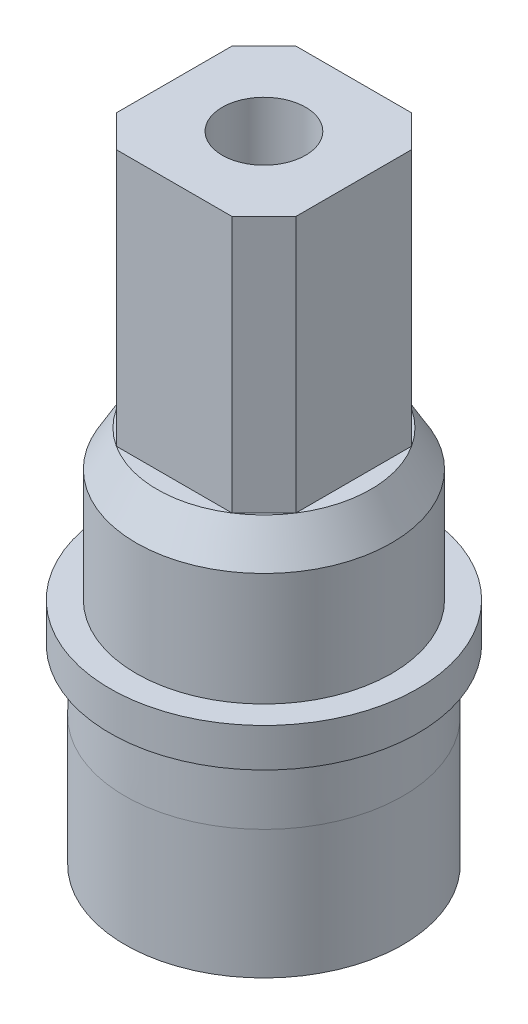
from build123d import *
from build123d.topology import SkipClean

# Parameters (mm, degrees)
SKETCH2_R                = 1.295
BOSS_EXTRUDE1_DEPTH      = 7.7
SKETCH3_R                = 2.7
BOSS_EXTRUDE4_DEPTH      = 6
SKETCH5_R                = 4.484484463
CUT_EXTRUDE1_DEPTH       = 1
SKETCH8_R                = 4.315
BOSS_EXTRUDE8_DEPTH      = 8
CUT_EXTRUDE4_DEPTH       = 10.2
SKETCH14_W               = 2.622578867
SKETCH14_H               = 4.71707074
CUT_EXTRUDE11_DEPTH      = 19.337852928
CUT_EXTRUDE11_DEPTH_BACK = 19.337852928
SKETCH16_R               = 1.295
BOSS_EXTRUDE9_DEPTH      = 5
CUT_EXTRUDE12_DEPTH      = 14
SKETCH22_R               = 4.315
CUT_EXTRUDE14_DEPTH      = 4


with BuildPart() as part:
    # Sketch1 → Revolve1 (revolve)
    with BuildSketch(Plane.XY, mode=Mode.PRIVATE) as revolve1_sk:
        Polygon((-2.7, 0), (-2.7, 5.54), (-1.295, 5.54), (-1.295, 8.3), (-3.32, 8.3), (-3.97, 7.184383121), (-3.97, 3.67), (-4.785, 3.67), (-4.785, 2.47), (-4.28, 2.47), (-4.325, 0), align=None)
    revolve(revolve1_sk.sketch.rotate(Axis((0, 0, 0), (0, 1, 0)), 270), axis=Axis((0, 0, 0), (0, 1, 0)))

    # Sketch2 → Boss-Extrude1 (add)
    with BuildSketch(Plane(origin=(0, 8.3, 0), x_dir=(1, 0, 0), z_dir=(0, 1, 0))):
        Polygon((1.799527716, 2.79), (-1.799527716, 2.79), (-2.79, 1.799527716), (-2.79, -1.799527716), (-1.799527716, -2.79), (1.799527716, -2.79), (2.79, -1.799527716), (2.79, 1.799527716), align=None)
        with Locations(Location((0, 0, 0), (0, 0, 90))):
            Circle(SKETCH2_R, mode=Mode.SUBTRACT)
    extrude(amount=BOSS_EXTRUDE1_DEPTH)

    # Sketch3 → Boss-Extrude4 (add)
    with BuildSketch(Plane.XZ.offset(-5.54)):
        with Locations(Location((0, 0, 0), (0, 0, 270))):
            Circle(SKETCH3_R)
    extrude(amount=BOSS_EXTRUDE4_DEPTH)

    # Sketch5 → Cut-Extrude1 (cut)
    with BuildSketch(Plane.XZ.offset(0.46)):
        Circle(SKETCH5_R)
    extrude(amount=-CUT_EXTRUDE1_DEPTH, mode=Mode.SUBTRACT)


with BuildPart() as body_2:
    # Sketch8 → Boss-Extrude8 (new body)
    with BuildSketch(Plane.XZ.offset(-0.54)):
        with Locations(Location((0, 0, 0), (0, 0, 270))):
            Circle(SKETCH8_R)
    extrude(amount=BOSS_EXTRUDE8_DEPTH)


with BuildPart() as cut_extrude4_tool:
    # Sketch13 → Cut-Extrude4 (new body)
    with BuildSketch(Plane.XZ.offset(7.46)):
        with BuildLine():
            ThreePointArc((1.6, 0), (-0.71250829, 1.432596222), (-0.96541492, -1.275920857))
            Line((-0.96541492, -1.275920857), (1.145236615, -1.117333029))
            ThreePointArc((1.145236615, -1.117333029), (1.481954551, -0.603167231), (1.6, 0))
        make_face()
    extrude(amount=-CUT_EXTRUDE4_DEPTH)


with BuildPart() as part_1:
    add(part.part)

    # Cut-Extrude4: cut by cut_extrude4_tool
    add(cut_extrude4_tool.part, mode=Mode.SUBTRACT)

    # Sketch14 → Cut-Extrude11 (cut, two sides)
    with BuildSketch(Plane.ZY.offset(2.79)) as cut_extrude11_sk:
        Polygon((-1.799527716, 11.28292926), (1.799527716, 11.28292926), (1.799527716, 16), (-1.799527716, 16), (-1.799527716, 11.405412722), align=None)
        with Locations((3.11081715, 13.64146463)):
            Rectangle(SKETCH14_W, SKETCH14_H)
        Polygon((-3.994671482, 11.28292926), (-1.799527716, 11.28292926), (-1.799527716, 11.405412722), (-1.799527716, 16), (-3.994671482, 16), align=None)
    extrude(amount=CUT_EXTRUDE11_DEPTH, mode=Mode.SUBTRACT)
    extrude(cut_extrude11_sk.sketch, amount=-CUT_EXTRUDE11_DEPTH_BACK, mode=Mode.SUBTRACT)

    # Sketch16 → Boss-Extrude9 (add)
    with BuildSketch(Plane(origin=(0, 11.28292926, 0), x_dir=(1, 0, 0), z_dir=(0, 1, 0))):
        Polygon((-2.79, -1.799527716), (-2.79, 1.799527716), (-1.799527716, 2.79), (1.799527716, 2.79), (2.79, 1.799527716), (2.79, -1.799527716), (1.799527716, -2.79), (-1.799527716, -2.79), align=None)
        with Locations(Location((0, 0, 0), (0, 0, 90))):
            Circle(SKETCH16_R, mode=Mode.SUBTRACT)
    extrude(amount=BOSS_EXTRUDE9_DEPTH)

    # Sketch21 → Cut-Extrude12 (cut)
    with SkipClean():  # the faces are left unmerged after this step: merging them gives an invalid solid
        with BuildSketch(Plane.XZ.offset(7.46)):
            with BuildLine():
                Line((1.145236615, -1.117333029), (-0.96541492, -1.275920857))
                ThreePointArc((-0.96541492, -1.275920857), (-0.11988113, 1.59550259), (1.145236615, -1.117333029))
            make_face()
        extrude(amount=-CUT_EXTRUDE12_DEPTH, mode=Mode.SUBTRACT)


with BuildPart() as body_2_1:
    add(body_2.part)

    # Cut-Extrude4: cut by cut_extrude4_tool
    add(cut_extrude4_tool.part, mode=Mode.SUBTRACT)

    # Sketch22 → Cut-Extrude14 (cut)
    with BuildSketch(Plane.XZ.offset(7.46)):
        with Locations(Location((0, 0, 0), (0, 0, 270))):
            Circle(SKETCH22_R)
        with BuildLine():
            ThreePointArc((1.6, 0), (1.481954551, -0.603167231), (1.145236615, -1.117333029))
            ThreePointArc((1.145236615, -1.117333029), (0.11988113, -1.59550259), (-0.96541492, -1.275920857))
            ThreePointArc((-0.96541492, -1.275920857), (-0.71250829, 1.432596222), (1.6, 0))
        make_face(mode=Mode.SUBTRACT)
        with BuildLine():
            ThreePointArc((-0.96541492, -1.275920857), (0.11988113, -1.59550259), (1.145236615, -1.117333029))
            Line((1.145236615, -1.117333029), (-0.96541492, -1.275920857))
        make_face()
        with BuildLine():
            Line((-0.96541492, -1.275920857), (1.145236615, -1.117333029))
            ThreePointArc((1.145236615, -1.117333029), (1.481954551, -0.603167231), (1.6, 0))
            ThreePointArc((1.6, 0), (-0.71250829, 1.432596222), (-0.96541492, -1.275920857))
        make_face()
    extrude(amount=-CUT_EXTRUDE14_DEPTH, mode=Mode.SUBTRACT)


solid = Compound([part_1.part, body_2_1.part])
